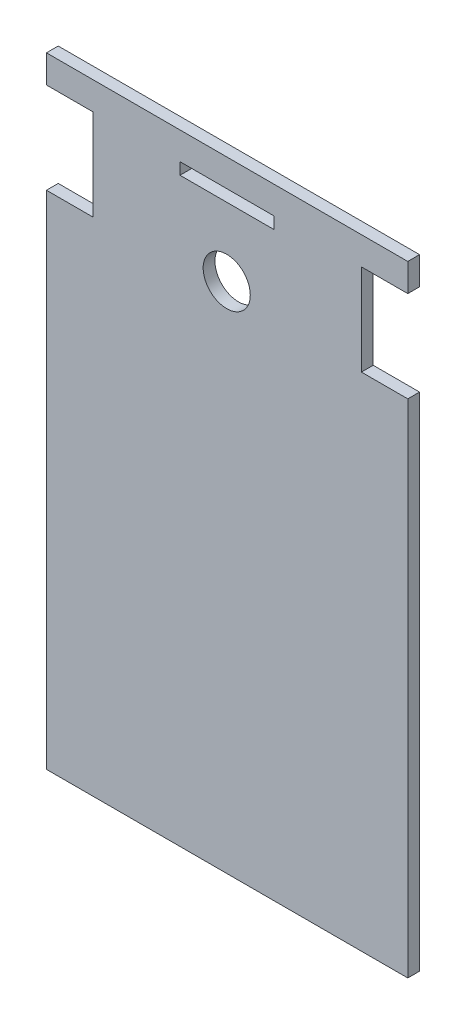
from build123d import *

# Parameters (mm, degrees)
MODEL_R                 = 6
MODEL_W                 = 24
MODEL_H                 = 3
SALIENTE_EXTRUIR1_DEPTH = 3


with BuildPart() as part:
    # Model → Saliente-Extruir1 (new body)
    with BuildSketch(Plane.XY):
        Polygon((54, 89), (54, 81.9), (65.8, 81.9), (65.8, 58.7), (54, 58.7), (54, -69), (146, -69), (146, 58.7), (134.2, 58.7), (134.2, 81.9), (146, 81.9), (146, 89), align=None)
        with Locations((99.899304233, 61.529562992)):
            Circle(MODEL_R, mode=Mode.SUBTRACT)
        with Locations((100, 80.5)):
            Rectangle(MODEL_W, MODEL_H, mode=Mode.SUBTRACT)
    extrude(amount=SALIENTE_EXTRUIR1_DEPTH)


solid = part.part
